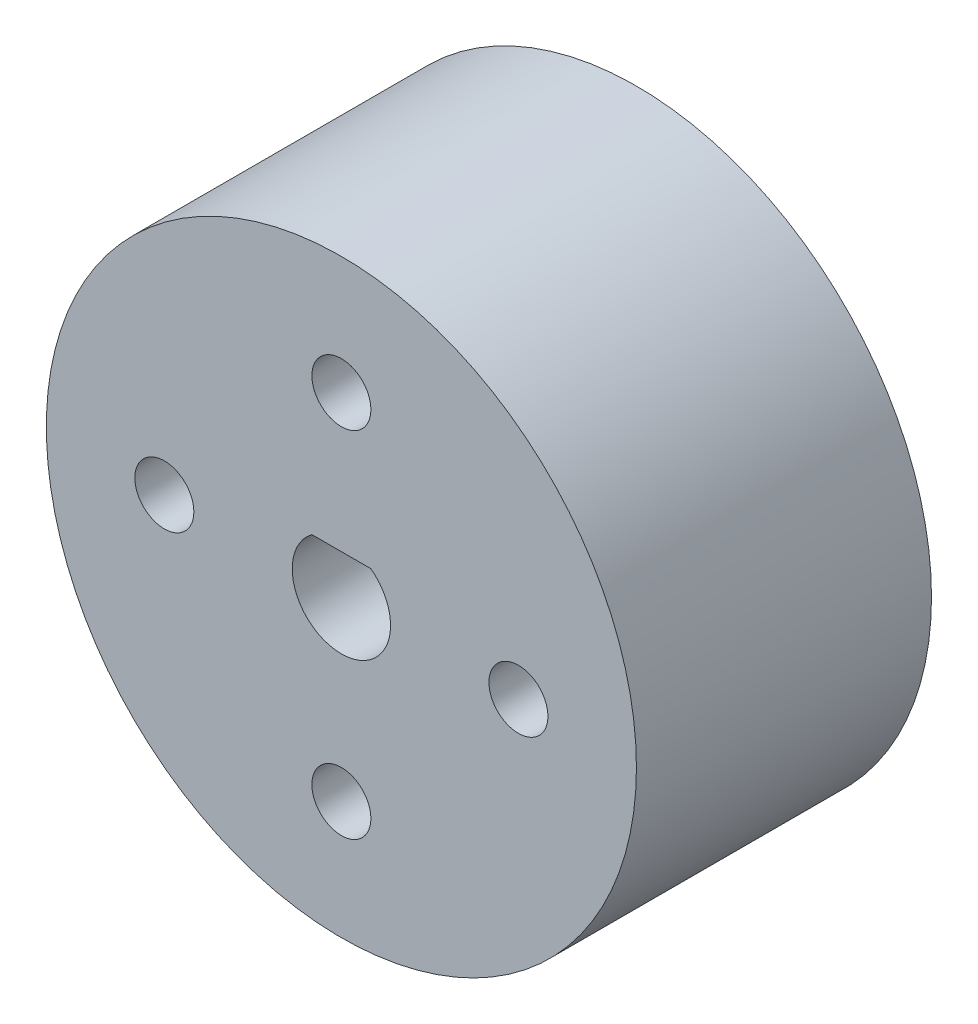
from build123d import *

# Parameters (mm, degrees)
SKETCH1_R           = 15
BOSS_EXTRUDE1_DEPTH = 15
CUT_EXTRUDE1_DEPTH  = 15
SKETCH3_R           = 1.5
CUT_EXTRUDE2_DEPTH  = 15


with BuildPart() as part:
    # Sketch1 → Boss-Extrude1 (new body)
    with BuildSketch(Plane.XY):
        Circle(SKETCH1_R)
    extrude(amount=BOSS_EXTRUDE1_DEPTH)

    # Sketch2 → Cut-Extrude1 (cut)
    with BuildSketch(Plane.XY.offset(15)):
        with BuildLine():
            Line((-1.5, 2), (1.5, 2))
            ThreePointArc((1.5, 2), (0, -2.5), (-1.5, 2))
        make_face()
    extrude(amount=-CUT_EXTRUDE1_DEPTH, mode=Mode.SUBTRACT)

    # Sketch3 → Cut-Extrude2 (cut)
    with BuildSketch(Plane.XY.offset(15)):
        with Locations((0, 9)):
            Circle(SKETCH3_R)
        with Locations((9, 0)):
            Circle(SKETCH3_R)
        with Locations((0, -9)):
            Circle(SKETCH3_R)
        with Locations((-9, 0)):
            Circle(SKETCH3_R)
    extrude(amount=-CUT_EXTRUDE2_DEPTH, mode=Mode.SUBTRACT)


solid = part.part
